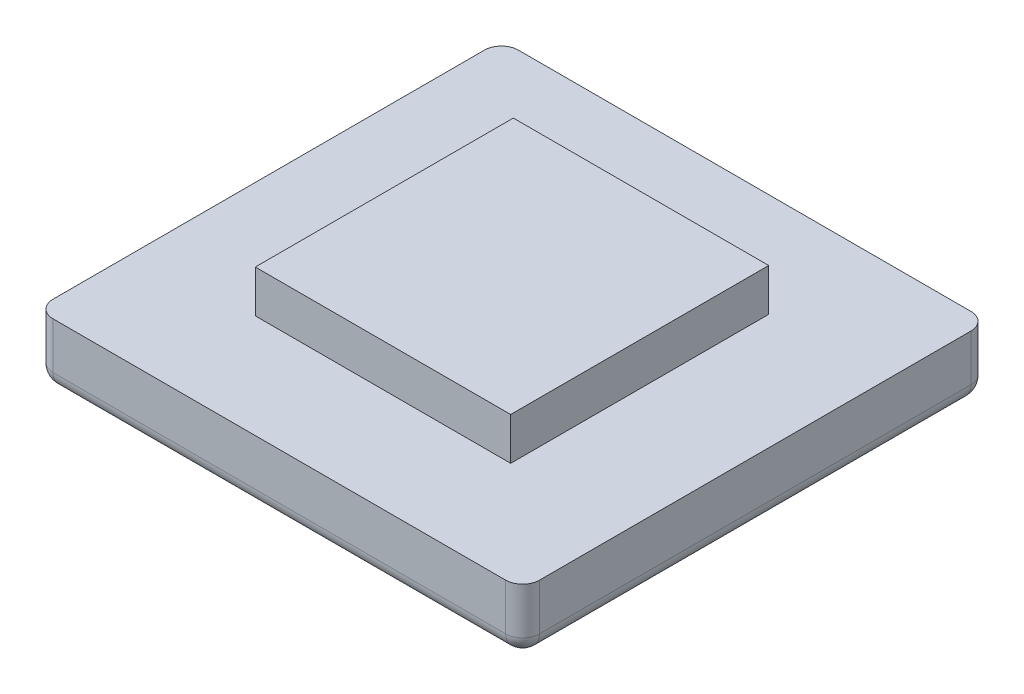
from build123d import *

# Parameters (mm, degrees)
SKETCH2_W           = 115
SKETCH2_H           = 110
BOSS_EXTRUDE1_DEPTH = 15
SKETCH3_W           = 60.365616492
SKETCH3_H           = 60.987942435
BOSS_EXTRUDE2_DEPTH = 10
FILLET2_R           = 4


with BuildPart() as part:
    # Sketch2 → Boss-Extrude1 (new body)
    with BuildSketch(Plane(origin=(0, 0, 0), x_dir=(1, 0, 0), z_dir=(0, 1, 0))):
        with Locations((36.364864865, 1.101351351)):
            Rectangle(SKETCH2_W, SKETCH2_H)
    extrude(amount=BOSS_EXTRUDE1_DEPTH)

    # Sketch3 → Boss-Extrude2 (add)
    with BuildSketch(Plane(origin=(0, 15, 0), x_dir=(1, 0, 0), z_dir=(0, 1, 0))):
        with Locations((36.364864865, 1.101351351)):
            Rectangle(SKETCH3_W, SKETCH3_H)
    extrude(amount=BOSS_EXTRUDE2_DEPTH)

    # Fillet2
    fillet2_edges = [part.edges().sort_by_distance(p)[0] for p in [
        (36.364864865, 0, -56.101351351),
        (93.864864865, 0, -1.101351351),
        (36.364864865, 0, 53.898648649),
        (-21.135135135, 0, -1.101351351),
        (-21.135135135, 7.5, -56.101351351),
        (93.864864865, 7.5, -56.101351351),
        (93.864864865, 7.5, 53.898648649),
        (-21.135135135, 7.5, 53.898648649),
    ]]
    fillet(fillet2_edges, radius=FILLET2_R)


solid = part.part
